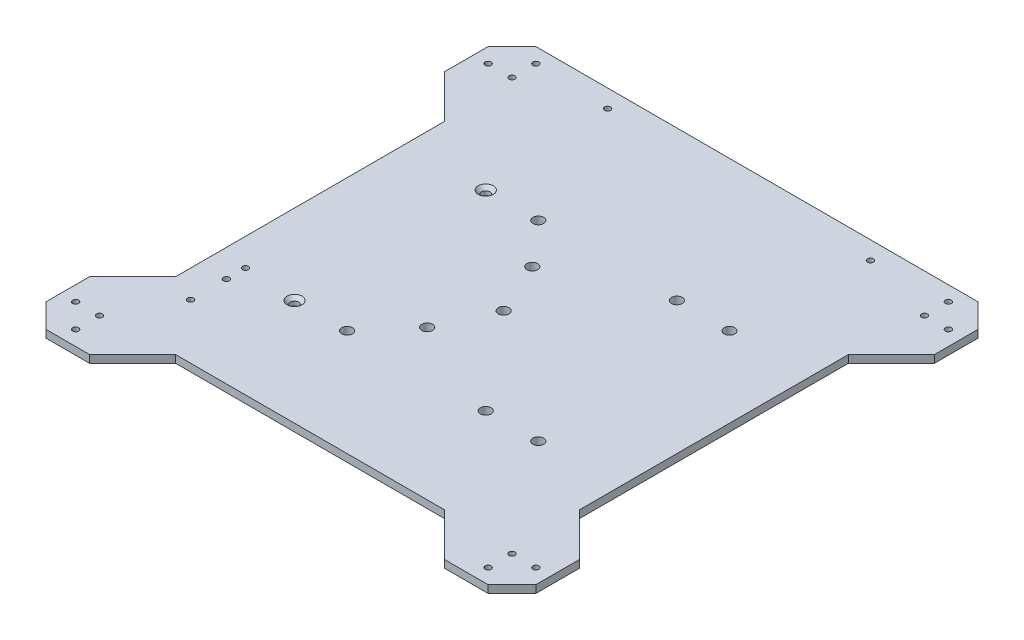
from build123d import *

# Parameters (mm, degrees)
BOSS_EXTRUDE1_DEPTH                             = 3.175
SKETCH2_R                                       = 1.5
SKETCH2_R_2                                     = 2.25
CUT_EXTRUDE1_DEPTH                              = 4.175
M3X0_5_TAPPED_HOLE1_D                           = 2.5
SKETCH5_R                                       = 1.25
CUT_EXTRUDE2_DEPTH                              = 4.175
SKETCH6_R                                       = 1.25
CUT_EXTRUDE3_DEPTH                              = 10
CSK_FOR_M3_FLAT_HEAD_MACHINE_SCREW1_D           = 3.4
CSK_FOR_M3_FLAT_HEAD_MACHINE_SCREW1_CSINK_D     = 6.3
CSK_FOR_M3_FLAT_HEAD_MACHINE_SCREW1_CSINK_ANGLE = 90
CUT_EXTRUDE4_DEPTH                              = 10


with BuildPart() as part:
    # Sketch1 → Boss-Extrude1 (new body)
    with BuildSketch(Plane(origin=(0, 0, 0), x_dir=(1, 0, 0), z_dir=(0, 1, 0))):
        Polygon((-92.5, 102.5), (92.5, 102.5), (102.5, 92.5), (102.5, -92.5), (92.5, -102.5), (-92.5, -102.5), (-102.5, -92.5), (-102.5, 92.5), align=None)
    extrude(amount=BOSS_EXTRUDE1_DEPTH)

    # Sketch2 → Cut-Extrude1 (cut, through all)
    with BuildSketch(Plane(origin=(0, 3.175, 0), x_dir=(1, 0, 0), z_dir=(0, 1, 0))):
        with Locations(Location((-51, -40, 0), (0, 0, 270))):  # turned: the seam where the file's is
            Circle(SKETCH2_R)
        with Locations(Location((-29, -40, 0), (0, 0, 270))):  # turned: the seam where the file's is
            Circle(SKETCH2_R_2)
        with Locations(Location((-51, 40, 0), (0, 0, 270))):  # turned: the seam where the file's is
            Circle(SKETCH2_R)
        with Locations(Location((-29, 40, 0), (0, 0, 270))):  # turned: the seam where the file's is
            Circle(SKETCH2_R_2)
        with Locations(Location((29, 40, 0), (0, 0, 270))):  # turned: the seam where the file's is
            Circle(SKETCH2_R_2)
        with Locations(Location((51, 40, 0), (0, 0, 270))):  # turned: the seam where the file's is
            Circle(SKETCH2_R_2)
        with Locations(Location((29, -40, 0), (0, 0, 270))):  # turned: the seam where the file's is
            Circle(SKETCH2_R_2)
        with Locations(Location((51, -40, 0), (0, 0, 270))):  # turned: the seam where the file's is
            Circle(SKETCH2_R_2)
        with Locations(Location((-3.5, 0, 0), (0, 0, 270))):  # turned: the seam where the file's is
            Circle(SKETCH2_R_2)
        with Locations(Location((-13.5, 22, 0), (0, 0, 270))):  # turned: the seam where the file's is
            Circle(SKETCH2_R_2)
        with Locations(Location((-13.5, -22, 0), (0, 0, 270))):  # turned: the seam where the file's is
            Circle(SKETCH2_R_2)
    extrude(amount=-CUT_EXTRUDE1_DEPTH, mode=Mode.SUBTRACT)

    # M3x0.5 Tapped Hole1 (through all)
    with Locations(Plane(origin=(0, 3.175, 0), x_dir=(-1, 0, 0), z_dir=(0, 1, 0))):
        with Locations((96.3, -86.3), (86.3, -96.3), (-86.3, -96.3), (-96.3, -86.3), (-96.3, 86.3), (-86.3, 96.3), (86.3, 96.3), (96.3, 86.3), (-86.3, 86.3), (-86.3, -86.3), (86.3, -86.3), (86.3, 86.3)):
            Hole(M3X0_5_TAPPED_HOLE1_D / 2)

    # Sketch5 → Cut-Extrude2 (cut, through all)
    with BuildSketch(Plane(origin=(0, 3.175, 0), x_dir=(1, 0, 0), z_dir=(0, 1, 0))):
        with Locations(Location((-55, 95, 0), (0, 0, 270))):  # turned: the seam where the file's is
            Circle(SKETCH5_R)
        with Locations(Location((55, 95, 0), (0, 0, 270))):  # turned: the seam where the file's is
            Circle(SKETCH5_R)
        with Locations(Location((-55, -95, 0), (0, 0, 270))):  # turned: the seam where the file's is
            Circle(SKETCH5_R)
        with Locations(Location((55, -95, 0), (0, 0, 270))):  # turned: the seam where the file's is
            Circle(SKETCH5_R)
    extrude(amount=-CUT_EXTRUDE2_DEPTH, mode=Mode.SUBTRACT)

    # Sketch6 → Cut-Extrude3 (cut)
    with BuildSketch(Plane(origin=(0, 3.175, 0), x_dir=(1, 0, 0), z_dir=(0, 1, 0))):
        with Locations(Location((-73, -46.5, 0), (0, 0, 270))):  # turned: the seam where the file's is
            Circle(SKETCH6_R)
        with Locations(Location((-73, -38.5, 0), (0, 0, 270))):  # turned: the seam where the file's is
            Circle(SKETCH6_R)
        with Locations(Location((-73, -61.5, 0), (0, 0, 270))):  # turned: the seam where the file's is
            Circle(SKETCH6_R)
    extrude(amount=-CUT_EXTRUDE3_DEPTH, mode=Mode.SUBTRACT)

    # CSK for M3 Flat Head Machine Screw1 (through all)
    with Locations(Plane(origin=(0, 3.175, 0), x_dir=(-1, 0, 0), z_dir=(0, 1, 0))):
        with Locations((51, -40), (51, 40)):
            CounterSinkHole(CSK_FOR_M3_FLAT_HEAD_MACHINE_SCREW1_D / 2, CSK_FOR_M3_FLAT_HEAD_MACHINE_SCREW1_CSINK_D / 2, counter_sink_angle=CSK_FOR_M3_FLAT_HEAD_MACHINE_SCREW1_CSINK_ANGLE)

    # Sketch9 → Cut-Extrude4 (cut)
    with BuildSketch(Plane(origin=(0, 3.175, 0), x_dir=(1, 0, 0), z_dir=(0, 1, 0))):
        Polygon((-102.5, 74.215728753), (-84.5, 56.215728753), (-84.5, -56.215728753), (-102.5, -74.215728753), align=None)
        Polygon((102.5, 74.215728753), (84.5, 56.215728753), (84.5, -56.215728753), (102.5, -74.215728753), align=None)
        Polygon((-74.215728753, -102.5), (-56.215728753, -84.5), (56.215728753, -84.5), (74.215728753, -102.5), align=None)
    extrude(amount=-CUT_EXTRUDE4_DEPTH, mode=Mode.SUBTRACT)


solid = part.part
